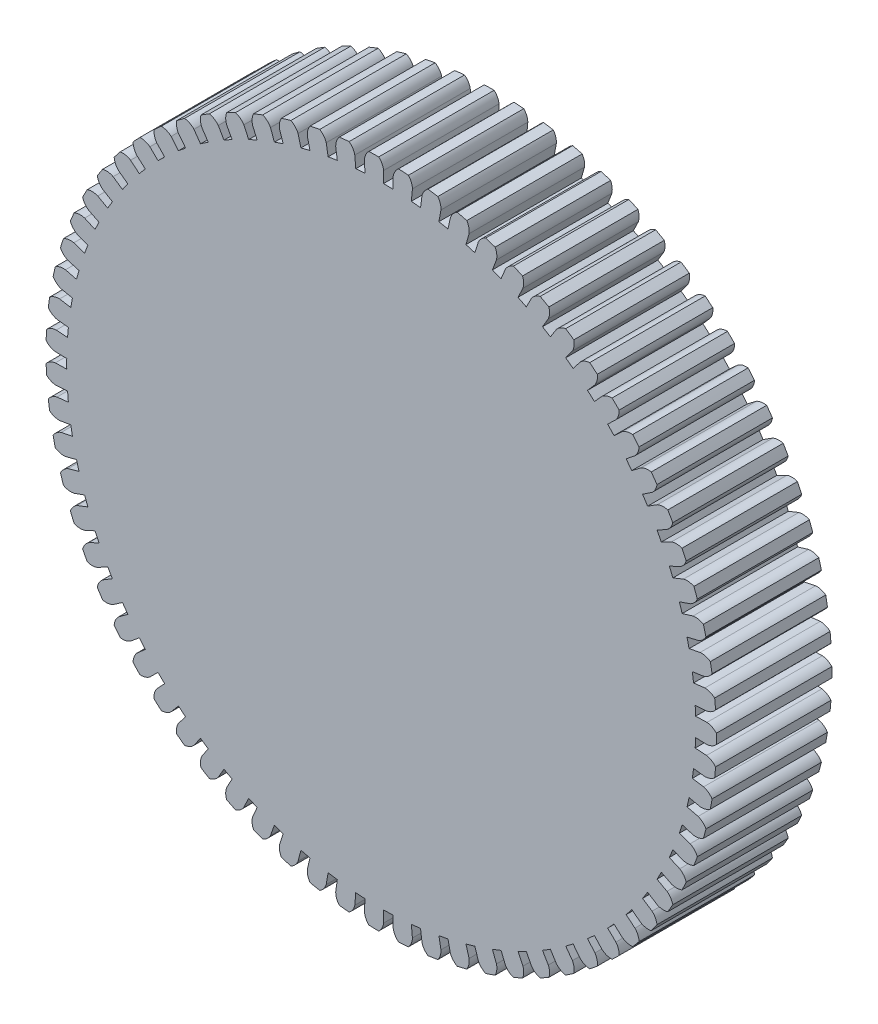
from build123d import *

# Parameters (mm, degrees)
BOSS_EXTRUDE6_DEPTH = 22
CIRPATTERN1_COUNT   = 71


with BuildPart() as part:
    # Sketch1 → Boss-Extrude6 (new, symmetric)
    with BuildSketch(Plane.XY):
        with BuildLine():
            Line((119.847837521, -3.536359936), (124.195945054, -3.6646599))
            ThreePointArc((124.195945054, -3.6646599), (126.153047737, -3.101611156), (127.786099401, -1.88488725))
            ThreePointArc((127.786099401, -1.88488725), (127.8, 0), (127.786099401, 1.88488725))
            ThreePointArc((127.786099401, 1.88488725), (126.153047737, 3.101611156), (124.195945054, 3.6646599))
            Line((124.195945054, 3.6646599), (119.847837521, 3.536359936))
            ThreePointArc((119.847837521, 3.536359936), (119.818499451, 4.420089297), (119.78264506, 5.303578272))
            Line((119.78264506, 5.303578272), (0, 0))
            Line((0, 0), (119.78264506, -5.303578272))
            ThreePointArc((119.78264506, -5.303578272), (119.818499451, -4.420089297), (119.847837521, -3.536359936))
        make_face()
    boss_extrude6 = extrude(amount=BOSS_EXTRUDE6_DEPTH, both=True)

    # CirPattern1: Boss-Extrude6 ×71 about axis
    cirpattern1_axis = Axis((0, 0, 0), (0, 0, 1))
    for i in range(1, CIRPATTERN1_COUNT):
        add(boss_extrude6.rotate(cirpattern1_axis, i * 360 / CIRPATTERN1_COUNT))


solid = part.part
